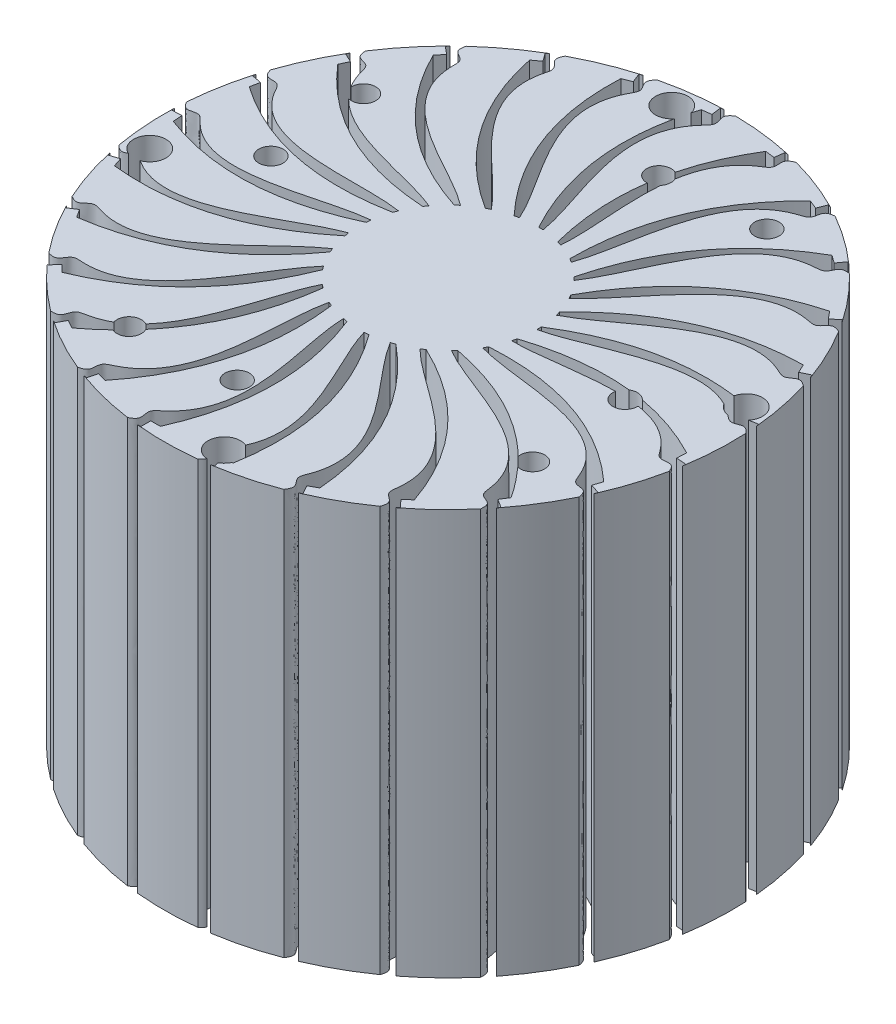
from build123d import *

# Parameters (mm, degrees)
SKETCH1_R             = 35
BOSS_EXTRUDE1_DEPTH   = 50
F_3_0MM_DOWEL_HOLE1_D = 3
F_4_0MM_DOWEL_HOLE1_D = 4
CUT_EXTRUDE1_DEPTH    = 50
F_3_0MM_DOWEL_HOLE2_D = 3


with BuildPart() as part:
    # Sketch1 → Boss-Extrude1 (new body)
    with BuildSketch(Plane(origin=(0, 0, 0), x_dir=(1, 0, 0), z_dir=(0, 1, 0))):
        Circle(SKETCH1_R)
    extrude(amount=BOSS_EXTRUDE1_DEPTH)

    # Ø3.0mm Dowel Hole1 (through all)
    with Locations(Plane(origin=(0, 0, 0), x_dir=(-1, 0, 0), z_dir=(0, -1, 0))):
        with Locations((-23.909893186, -2.077741039), (-2.077741039, 23.909893186), (23.909893186, 2.077741039), (2.077741039, -23.909893186)):
            Hole(F_3_0MM_DOWEL_HOLE1_D / 2)

    # Ø4.0mm Dowel Hole1 (through all)
    with Locations(Plane(origin=(0, 50, 0), x_dir=(1, 0, 0), z_dir=(0, 1, 0))):
        with Locations((32.173858082, 4.592695957), (4.592695957, -32.173858082), (-32.173858082, -4.592695957), (-4.592695957, 32.173858082)):
            Hole(F_4_0MM_DOWEL_HOLE1_D / 2)

    # Sketch8 → Cut-Extrude1 (cut)
    with BuildSketch(Plane.XZ):
        with BuildLine():
            Line((-24.683839582, -22.859251968), (-23.934371092, -23.766805828))
            Line((-23.934371092, -23.766805828), (-24.872452855, -24.541484614))
            add(Edge.make_bspline(
                [(-6.973882119, -8.506760146), (-11.603132375, -12.100319497), (-22.836843906, -15.274494233), (-22.278409767, -24.247907257), (-24.657287028, -24.736059685), (-22.696146479, -27.492446901), (-24.872452855, -24.541484614)],
                knots=[0, 0, 0, 0, 0.801043671, 0.845230591, 0.897132706, 1, 1, 1, 1], degree=3))
            add(Edge.make_bspline(
                [(-6.973882119, -8.506760146), (-7.39163301, -8.14639561)],
                knots=[0, 0, 1, 1], degree=1))
            add(Edge.make_bspline(
                [(-7.39163301, -8.14639561), (-19.393875963, -12.067652387), (-24.683839582, -22.859251968)],
                knots=[0, 0, 0, 1, 1, 1], degree=2))
        make_face()
        with BuildLine():
            Line((-29.593216163, -16.002465252), (-29.092993071, -17.067891873))
            Line((-29.092993071, -17.067891873), (-30.194258051, -17.584941252))
            add(Edge.make_bspline(
                [(-8.870330009, -6.505170676), (-14.247825725, -8.834584028), (-25.917994708, -9.115325775), (-27.608701877, -17.945699451), (-30.034240907, -17.826912955), (-28.82019882, -20.98441902), (-30.194258051, -17.584941252)],
                knots=[0, 0, 0, 0, 0.801043671, 0.845230591, 0.897132706, 1, 1, 1, 1], degree=3))
            add(Edge.make_bspline(
                [(-8.870330009, -6.505170676), (-9.185337472, -6.052237233)],
                knots=[0, 0, 1, 1], degree=1))
            add(Edge.make_bspline(
                [(-9.185337472, -6.052237233), (-21.785684797, -6.865464072), (-29.593216163, -16.002465252)],
                knots=[0, 0, 0, 1, 1, 1], degree=2))
        make_face()
        with BuildLine():
            Line((-32.643142137, -8.140184791), (-32.423595299, -9.2965395))
            Line((-32.423595299, -9.2965395), (-33.618846967, -9.523471359))
            add(Edge.make_bspline(
                [(-10.209422442, -4.094837408), (-15.997275785, -5.013739153), (-27.370622583, -2.383407874), (-31.20423771, -10.515897348), (-33.524032971, -9.797635721), (-33.133372075, -13.157862916), (-33.618846967, -9.523471359)],
                knots=[0, 0, 0, 0, 0.801043671, 0.845230591, 0.897132706, 1, 1, 1, 1], degree=3))
            add(Edge.make_bspline(
                [(-10.209422442, -4.094837408), (-10.401893399, -3.577794531)],
                knots=[0, 0, 1, 1], degree=1))
            add(Edge.make_bspline(
                [(-10.401893399, -3.577794531), (-22.808618934, -1.231893399), (-32.643142137, -8.140184791)],
                knots=[0, 0, 0, 1, 1, 1], degree=2))
        make_face()
        with BuildLine():
            Line((-33.641979438, 0.233573418), (-33.716903789, -0.941051359))
            Line((-33.716903789, -0.941051359), (-34.931040086, -0.863606735))
            add(Edge.make_bspline(
                [(-10.907019315, -1.427210446), (-16.741558174, -0.877862608), (-27.103453579, 4.498268308), (-32.839096527, -2.425342741), (-34.90738675, -1.152737001), (-35.364653708, -4.504549894), (-34.931040086, -0.863606735)],
                knots=[0, 0, 0, 0, 0.801043671, 0.845230591, 0.897132706, 1, 1, 1, 1], degree=3))
            add(Edge.make_bspline(
                [(-10.907019315, -1.427210446), (-10.964860109, -0.878545841)],
                knots=[0, 0, 1, 1], degree=1))
            add(Edge.make_bspline(
                [(-10.964860109, -0.878545841), (-22.398403658, 4.479081666), (-33.641979438, 0.233573418)],
                knots=[0, 0, 0, 1, 1, 1], degree=2))
        make_face()
        with BuildLine():
            Line((-32.526967444, 8.59265535), (-32.891655212, 7.473566498))
            Line((-32.891655212, 7.473566498), (-34.04838749, 7.850521476))
            add(Edge.make_bspline(
                [(-10.919288052, 1.330093398), (-16.433906891, 3.313173273), (-25.133274907, 11.09730175), (-32.410554135, 5.817605071), (-34.09738104, 7.564592424), (-35.373844085, 4.431800564), (-34.04838749, 7.850521476)],
                knots=[0, 0, 0, 0, 0.801043671, 0.845230591, 0.897132706, 1, 1, 1, 1], degree=3))
            add(Edge.make_bspline(
                [(-10.919288052, 1.330093398), (-10.838864332, 1.875905115)],
                knots=[0, 0, 1, 1], degree=1))
            add(Edge.make_bspline(
                [(-10.838864332, 1.875905115), (-20.580814305, 9.908619557), (-32.526967444, 8.59265535)],
                knots=[0, 0, 0, 1, 1, 1], degree=2))
        make_face()
        with BuildLine():
            Line((-29.368166459, 16.411829144), (-29.999702971, 15.418592687))
            Line((-29.999702971, 15.418592687), (-31.026349486, 16.071372551))
            add(Edge.make_bspline(
                [(-10.245457761, 4.003822581), (-15.093652799, 7.296030292), (-21.583880138, 16.99905091), (-29.945537429, 13.695011361), (-31.144911478, 15.806610686), (-33.160365743, 13.089684694), (-31.026349486, 16.071372551)],
                knots=[0, 0, 0, 0, 0.801043671, 0.845230591, 0.897132706, 1, 1, 1, 1], degree=3))
            add(Edge.make_bspline(
                [(-10.245457761, 4.003822581), (-10.031822846, 4.512486054)],
                knots=[0, 0, 1, 1], degree=1))
            add(Edge.make_bspline(
                [(-10.031822846, 4.512486054), (-17.470056699, 14.715562441), (-29.368166459, 16.411829144)],
                knots=[0, 0, 0, 1, 1, 1], degree=2))
        make_face()
        with BuildLine():
            Line((-24.364055568, 23.199787356), (-25.222759061, 22.394811992))
            Line((-25.222759061, 22.394811992), (-26.054811837, 23.282400182))
            add(Edge.make_bspline(
                [(-8.92786768, 6.425976867), (-12.805008991, 10.820450896), (-16.678290801, 21.832687182), (-25.598932475, 20.71190972), (-26.235492584, 23.055441466), (-28.863299666, 20.925095794), (-26.054811837, 23.282400182)],
                knots=[0, 0, 0, 0, 0.801043671, 0.845230591, 0.897132706, 1, 1, 1, 1], degree=3))
            add(Edge.make_bspline(
                [(-8.92786768, 6.425976867), (-8.594445036, 6.865530898)],
                knots=[0, 0, 1, 1], degree=1))
            add(Edge.make_bspline(
                [(-8.594445036, 6.865530898), (-13.261591179, 18.597872416), (-24.364055568, 23.199787356)],
                knots=[0, 0, 0, 1, 1, 1], degree=2))
        make_face()
        with BuildLine():
            Line((-17.82906146, 28.530017604), (-18.860976436, 27.963882897))
            Line((-18.860976436, 27.963882897), (-19.446154538, 29.030508983))
            add(Edge.make_bspline(
                [(-7.049306837, 8.444363393), (-9.711779374, 13.664982774), (-10.724743115, 25.294495425), (-19.643852447, 26.427402618), (-19.677601205, 28.855614067), (-22.752646319, 27.445706169), (-19.446154538, 29.030508983)],
                knots=[0, 0, 0, 0, 0.801043671, 0.845230591, 0.897132706, 1, 1, 1, 1], degree=3))
            add(Edge.make_bspline(
                [(-7.049306837, 8.444363393), (-6.617046637, 8.787189187)],
                knots=[0, 0, 1, 1], degree=1))
            add(Edge.make_bspline(
                [(-6.617046637, 8.787189187), (-8.219851114, 21.311609669), (-17.82906146, 28.530017604)],
                knots=[0, 0, 0, 1, 1, 1], degree=2))
        make_face()
        with BuildLine():
            Line((-10.17380185, 32.067601921), (-11.314089296, 31.775880196))
            Line((-11.314089296, 31.775880196), (-11.615623831, 32.954524137))
            add(Edge.make_bspline(
                [(-4.727812121, 9.932159511), (-6.008322942, 15.650893529), (-4.097320375, 27.166957493), (-12.454476924, 30.482364617), (-11.883293772, 32.842682312), (-15.212360526, 32.241801886), (-11.615623831, 32.954524137)],
                knots=[0, 0, 0, 0, 0.801043671, 0.845230591, 0.897132706, 1, 1, 1, 1], degree=3))
            add(Edge.make_bspline(
                [(-4.727812121, 9.932159511), (-4.223874862, 10.156716061)],
                knots=[0, 0, 1, 1], degree=1))
            add(Edge.make_bspline(
                [(-4.223874862, 10.156716061), (-2.661627572, 22.686260108), (-10.17380185, 32.067601921)],
                knots=[0, 0, 0, 1, 1, 1], degree=2))
        make_face()
        with BuildLine():
            Line((-1.879284853, 33.590260873), (-3.056296315, 33.591282078))
            Line((-3.056296315, 33.591282078), (-3.055240759, 34.807885342))
            add(Edge.make_bspline(
                [(-2.109251581, 10.795881519), (-1.927341482, 16.653401084), (2.787552072, 27.332419708), (-4.482540813, 32.62200754), (-3.342315288, 34.766124041), (-6.716226173, 35.012026614), (-3.055240759, 34.807885342)],
                knots=[0, 0, 0, 0, 0.801043671, 0.845230591, 0.897132706, 1, 1, 1, 1], degree=3))
            add(Edge.make_bspline(
                [(-2.109251581, 10.795881519), (-1.565301494, 10.888059112)],
                knots=[0, 0, 1, 1], degree=1))
            add(Edge.make_bspline(
                [(-1.565301494, 10.888059112), (3.063835819, 22.63544939), (-1.879284853, 33.590260873)],
                knots=[0, 0, 0, 1, 1, 1], degree=2))
        make_face()
        with BuildLine():
            Line((6.533314523, 33.002320197), (5.393535003, 33.296020167))
            Line((5.393535003, 33.296020167), (5.697114326, 34.474139097))
            add(Edge.make_bspline(
                [(0.641840992, 10.981258586), (2.274741931, 16.609514201), (9.497272371, 25.780485472), (3.771049824, 32.711889755), (5.408673158, 34.505082336), (2.20191337, 35.582316944), (5.697114326, 34.474139097)],
                knots=[0, 0, 0, 0, 0.801043671, 0.845230591, 0.897132706, 1, 1, 1, 1], degree=3))
            add(Edge.make_bspline(
                [(0.641840992, 10.981258586), (1.191625522, 10.935265366)],
                knots=[0, 0, 1, 1], degree=1))
            add(Edge.make_bspline(
                [(1.191625522, 10.935265366), (8.596787138, 21.162370139), (6.533314523, 33.002320197)],
                knots=[0, 0, 0, 1, 1, 1], degree=2))
        make_face()
        with BuildLine():
            Line((14.535401719, 30.34072237), (13.504470681, 30.908646855))
            Line((13.504470681, 30.908646855), (14.091498765, 31.974255904))
            add(Edge.make_bspline(
                [(3.352604336, 10.476642791), (6.333894942, 15.521990455), (15.610244118, 22.608668519), (11.787691532, 30.74636363), (13.819814778, 32.075959406), (10.981698599, 33.916839438), (14.091498765, 31.974255904)],
                knots=[0, 0, 0, 0, 0.801043671, 0.845230591, 0.897132706, 1, 1, 1, 1], degree=3))
            add(Edge.make_bspline(
                [(3.352604336, 10.476642791), (3.873678325, 10.295368679)],
                knots=[0, 0, 1, 1], degree=1))
            add(Edge.make_bspline(
                [(3.873678325, 10.295368679), (13.589570703, 18.359581343), (14.535401719, 30.34072237)],
                knots=[0, 0, 0, 1, 1, 1], degree=2))
        make_face()
        with BuildLine():
            Line((21.624176168, 25.77270537), (20.766870801, 26.579169587))
            Line((20.766870801, 26.579169587), (21.600462512, 27.465312621))
            add(Edge.make_bspline(
                [(5.852711219, 9.313740998), (9.995066041, 13.459162964), (20.742366817, 18.016265775), (19.063669228, 26.848930401), (21.362606609, 27.63138598), (19.071463316, 30.120242173), (21.600462512, 27.465312621)],
                knots=[0, 0, 0, 0, 0.801043671, 0.845230591, 0.897132706, 1, 1, 1, 1], degree=3))
            add(Edge.make_bspline(
                [(5.852711219, 9.313740998), (6.312333673, 9.008576114)],
                knots=[0, 0, 1, 1], degree=1))
            add(Edge.make_bspline(
                [(6.312333673, 9.008576114), (17.728471563, 14.40319253), (21.624176168, 25.77270537)],
                knots=[0, 0, 0, 1, 1, 1], degree=2))
        make_face()
        with BuildLine():
            Line((27.3542241, 19.585294507), (26.724412053, 20.579625343))
            Line((26.724412053, 20.579625343), (27.752189758, 21.230622735))
            add(Edge.make_bspline(
                [(7.985070732, 7.565622605), (13.02821038, 10.550646764), (24.571170324, 12.291834793), (25.141806475, 21.264480131), (27.563107301, 21.450630952), (25.962897854, 24.431079318), (27.752189758, 21.230622735)],
                knots=[0, 0, 0, 0, 0.801043671, 0.845230591, 0.897132706, 1, 1, 1, 1], degree=3))
            add(Edge.make_bspline(
                [(7.985070732, 7.565622605), (8.35436188, 7.155741581)],
                knots=[0, 0, 1, 1], degree=1))
            add(Edge.make_bspline(
                [(8.35436188, 7.155741581), (20.753427353, 9.541798158), (27.3542241, 19.585294507)],
                knots=[0, 0, 0, 1, 1, 1], degree=2))
        make_face()
        with BuildLine():
            Line((31.36550553, 12.167267561), (31.00276021, 13.286987551))
            Line((31.00276021, 13.286987551), (32.160144857, 13.661934742))
            add(Edge.make_bspline(
                [(9.615698884, 5.342128319), (15.242744347, 6.979194625), (26.856076833, 5.795062624), (29.640191557, 14.34390437), (32.031716591, 13.922053891), (31.222988034, 17.206821898), (32.160144857, 13.661934742)],
                knots=[0, 0, 0, 0, 0.801043671, 0.845230591, 0.897132706, 1, 1, 1, 1], degree=3))
            add(Edge.make_bspline(
                [(9.615698884, 5.342128319), (9.871454805, 4.853285488)],
                knots=[0, 0, 1, 1], degree=1))
            add(Edge.make_bspline(
                [(9.871454805, 4.853285488), (22.474368978, 4.080857516), (31.36550553, 12.167267561)],
                knots=[0, 0, 0, 1, 1, 1], degree=2))
        make_face()
        with BuildLine():
            Line((33.405976893, 3.984726445), (33.333090923, 5.159479466))
            Line((33.333090923, 5.159479466), (34.547359777, 5.234817144))
            add(Edge.make_bspline(
                [(10.64213731, 2.782968464), (16.499520628, 2.96921402), (27.453517264, -1.065834642), (32.276174394, 6.522048344), (34.487655324, 5.518702982), (34.521223046, 8.901396576), (34.547359777, 5.234817144)],
                knots=[0, 0, 0, 0, 0.801043671, 0.845230591, 0.897132706, 1, 1, 1, 1], degree=3))
            add(Edge.make_bspline(
                [(10.64213731, 2.782968464), (10.768287921, 2.245879618)],
                knots=[0, 0, 1, 1], degree=1))
            add(Edge.make_bspline(
                [(10.768287921, 2.245879618), (22.783163344, -1.636498412), (33.405976893, 3.984726445)],
                knots=[0, 0, 0, 1, 1, 1], degree=2))
        make_face()
        with BuildLine():
            Line((33.34742787, -4.448189688), (33.568980942, -3.292217689))
            Line((33.568980942, -3.292217689), (34.763837026, -3.521223268))
            add(Edge.make_bspline(
                [(10.99989111, 0.048944466), (16.719571346, -1.227333221), (26.325952239, -7.859761597), (32.88412649, -1.709611966), (34.776607835, -3.231408331), (35.650362654, 0.03666377), (34.763837026, -3.521223268)],
                knots=[0, 0, 0, 0, 0.801043671, 0.845230591, 0.897132706, 1, 1, 1, 1], degree=3))
            add(Edge.make_bspline(
                [(10.99989111, 0.048944466), (10.988509903, -0.502643128)],
                knots=[0, 0, 1, 1], degree=1))
            add(Edge.make_bspline(
                [(10.988509903, -0.502643128), (21.660407767, -7.251027126), (33.34742787, -4.448189688)],
                knots=[0, 0, 0, 1, 1, 1], degree=2))
        make_face()
        with BuildLine():
            Line((31.19353731, -12.601609703), (31.695608431, -11.537052699))
            Line((31.695608431, -11.537052699), (32.795974543, -12.056012271))
            add(Edge.make_bspline(
                [(10.666481297, -2.688154894), (15.889069907, -5.346762603), (23.544230815, -14.159830825), (31.42584798, -9.833851069), (32.880418177, -11.778478375), (34.539458864, -8.830372756), (32.795974543, -12.056012271)],
                knots=[0, 0, 0, 0, 0.801043671, 0.845230591, 0.897132706, 1, 1, 1, 1], degree=3))
            add(Edge.make_bspline(
                [(10.666481297, -2.688154894), (10.518283395, -3.219582958)],
                knots=[0, 0, 1, 1], degree=1))
            add(Edge.make_bspline(
                [(10.518283395, -3.219582958), (19.176649108, -12.409947139), (31.19353731, -12.601609703)],
                knots=[0, 0, 0, 1, 1, 1], degree=2))
        make_face()
        with BuildLine():
            Line((27.079642079, -19.963224236), (27.830684274, -19.056972258))
            Line((27.830684274, -19.056972258), (28.767420363, -19.833277685))
            add(Edge.make_bspline(
                [(9.662857236, -5.256347595), (14.060199769, -9.130235226), (19.283138779, -19.570185806), (27.992967865, -17.340193143), (28.918230919, -19.585463304), (31.258313846, -17.142564486), (28.767420363, -19.833277685)],
                knots=[0, 0, 0, 0, 0.801043671, 0.845230591, 0.897132706, 1, 1, 1, 1], degree=3))
            add(Edge.make_bspline(
                [(9.662857236, -5.256347595), (9.387154458, -5.734224549)],
                knots=[0, 0, 1, 1], degree=1))
            add(Edge.make_bspline(
                [(9.387154458, -5.734224549), (15.487951059, -16.789104532), (27.079642079, -19.963224236)],
                knots=[0, 0, 0, 1, 1, 1], degree=2))
        make_face()
        with BuildLine():
            Line((21.264233345, -26.07047597), (22.21705587, -25.379472163))
            Line((22.21705587, -25.379472163), (22.931303364, -26.36434532))
            add(Edge.make_bspline(
                [(8.052080317, -7.494264645), (11.347875571, -12.340021591), (13.810416215, -23.750874039), (22.801186628, -23.756987108), (23.139004859, -26.161821543), (26.013094008, -24.377625842), (22.931303364, -26.36434532)],
                knots=[0, 0, 0, 0, 0.801043671, 0.845230591, 0.897132706, 1, 1, 1, 1], degree=3))
            add(Edge.make_bspline(
                [(8.052080317, -7.494264645), (7.666196083, -7.888563724)],
                knots=[0, 0, 1, 1], degree=1))
            add(Edge.make_bspline(
                [(7.666196083, -7.888563724), (10.826088085, -20.113340742), (21.264233345, -26.07047597)],
                knots=[0, 0, 0, 1, 1, 1], degree=2))
        make_face()
        with BuildLine():
            Line((14.112714625, -30.539623818), (15.207448137, -30.107286493))
            Line((15.207448137, -30.107286493), (15.654328238, -31.238844177))
            add(Edge.make_bspline(
                [(5.935361578, -9.261289486), (7.922522615, -14.774439016), (7.469934409, -26.439207507), (16.176722978, -28.681042202), (15.905870024, -31.094336319), (19.133375805, -30.080951313), (15.654328238, -31.238844177)],
                knots=[0, 0, 0, 0, 0.801043671, 0.845230591, 0.897132706, 1, 1, 1, 1], degree=3))
            add(Edge.make_bspline(
                [(5.935361578, -9.261289486), (5.463542413, -9.547235427)],
                knots=[0, 0, 1, 1], degree=1))
            add(Edge.make_bspline(
                [(5.463542413, -9.547235427), (5.48398218, -22.173781781), (14.112714625, -30.539623818)],
                knots=[0, 0, 0, 1, 1, 1], degree=2))
        make_face()
        with BuildLine():
            Line((6.074442142, -33.089854785), (7.242300509, -32.943349286))
            Line((7.242300509, -32.943349286), (7.393734097, -34.150491566))
            add(Edge.make_bspline(
                [(3.445702243, -10.446393447), (3.999368427, -16.280524102), (0.660089152, -27.46626833), (8.53581633, -31.802961932), (7.673310878, -34.073079587), (11.051437233, -33.894179983), (7.393734097, -34.150491566)],
                knots=[0, 0, 0, 0, 0.801043671, 0.845230591, 0.897132706, 1, 1, 1, 1], degree=3))
            add(Edge.make_bspline(
                [(3.445702243, -10.446393447), (2.91759428, -10.606019216)],
                knots=[0, 0, 1, 1], degree=1))
            add(Edge.make_bspline(
                [(2.91759428, -10.606019216), (-0.202702493, -22.840962561), (6.074442142, -33.089854785)],
                knots=[0, 0, 0, 1, 1, 1], degree=2))
        make_face()
        with BuildLine():
            Line((-2.345509881, -33.56092848), (-1.177907496, -33.709460286))
            Line((-1.177907496, -33.709460286), (-1.33143555, -34.916337973))
            add(Edge.make_bspline(
                [(0.739536763, -10.975112089), (-0.175080788, -16.763643982), (-6.191231935, -26.7675225), (0.358572949, -32.926584602), (-1.041390611, -34.910885952), (2.275096214, -35.57771267), (-1.33143555, -34.916337973)],
                knots=[0, 0, 0, 0, 0.801043671, 0.845230591, 0.897132706, 1, 1, 1, 1], degree=3))
            add(Edge.make_bspline(
                [(0.739536763, -10.975112089), (0.188322969, -10.998387812)],
                knots=[0, 0, 1, 1], degree=1))
            add(Edge.make_bspline(
                [(0.188322969, -10.998387812), (-5.876650624, -22.07296166), (-2.345509881, -33.56092848)],
                knots=[0, 0, 0, 1, 1, 1], degree=2))
        make_face()
        with BuildLine():
            Line((-10.618084892, -31.92324561), (-9.524103241, -32.357481921))
            Line((-9.524103241, -32.357481921), (-9.972946205, -33.488262452))
            add(Edge.make_bspline(
                [(-2.013096532, -10.814224075), (-4.338529034, -16.193442459), (-12.653535149, -24.386874787), (-7.841200889, -31.981308865), (-9.690657698, -33.555112959), (-6.644197466, -35.025766824), (-9.972946205, -33.488262452)],
                knots=[0, 0, 0, 0, 0.801043671, 0.845230591, 0.897132706, 1, 1, 1, 1], degree=3))
            add(Edge.make_bspline(
                [(-2.013096532, -10.814224075), (-2.552781367, -10.699687252)],
                knots=[0, 0, 1, 1], degree=1))
            add(Edge.make_bspline(
                [(-2.552781367, -10.699687252), (-11.181347183, -19.9180354), (-10.618084892, -31.92324561)],
                knots=[0, 0, 0, 1, 1, 1], degree=2))
        make_face()
        with BuildLine():
            Line((-18.223486578, -28.279707813), (-17.271864552, -28.972363965))
            Line((-17.271864552, -28.972363965), (-17.987819972, -29.95599624))
            add(Edge.make_bspline(
                [(-4.639239568, -9.973838591), (-8.229371544, -14.60574739), (-18.320770213, -20.473910043), (-15.548283237, -29.026529873), (-17.731025123, -30.090948813), (-15.146011784, -32.273023234), (-17.987819972, -29.95599624)],
                knots=[0, 0, 0, 0, 0.801043671, 0.845230591, 0.897132706, 1, 1, 1, 1], degree=3))
            add(Edge.make_bspline(
                [(-4.639239568, -9.973838591), (-5.133485062, -9.728685991)],
                knots=[0, 0, 1, 1], degree=1))
            add(Edge.make_bspline(
                [(-5.133485062, -9.728685991), (-15.783478576, -16.511585722), (-18.223486578, -28.279707813)],
                knots=[0, 0, 0, 1, 1, 1], degree=2))
        make_face()
    extrude(amount=-CUT_EXTRUDE1_DEPTH, mode=Mode.SUBTRACT)

    # Ø3.0mm Dowel Hole2 (through all)
    with Locations(Plane(origin=(0, 50, 0), x_dir=(1, 0, 0), z_dir=(0, 1, 0))):
        with Locations((-24.858605813, 14.443414314), (14.443414314, 24.858605813), (24.858605813, -14.443414314), (-14.443414314, -24.858605813)):
            Hole(F_3_0MM_DOWEL_HOLE2_D / 2)


solid = part.part
